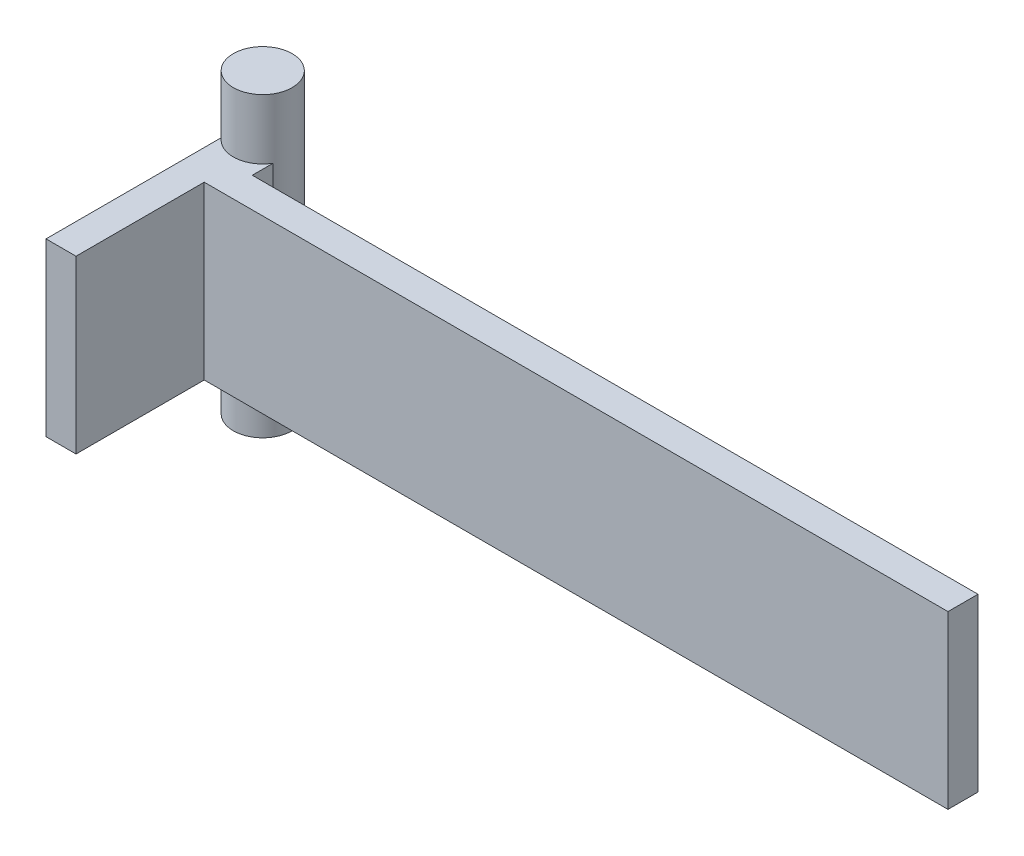
from build123d import *

# Parameters (mm, degrees)
SKETCH1_W                = 10
SKETCH1_H                = 28.53
BOSS_EXTRUDE1_DEPTH      = 5
SKETCH2_R                = 1.6
CUT_EXTRUDE2_DEPTH       = 43
SKETCH4_W                = 8
SKETCH4_H                = 28.530522497
BOSS_EXTRUDE2_DEPTH      = 5
BOSS_EXTRUDE2_DEPTH_BACK = 5
BOSS_EXTRUDE4_START      = -53
SKETCH6_W                = 5
SKETCH6_H                = 28.530522497
BOSS_EXTRUDE4_DEPTH      = 120.849702
SKETCH7_W                = 5
SKETCH7_H                = 28.530522497
BOSS_EXTRUDE5_DEPTH      = 26.35
SKETCH8_W                = 5
SKETCH8_H                = 7
BOSS_EXTRUDE6_DEPTH      = 21.504288
SKETCH9_W                = 5
SKETCH9_H                = 21.35
CUT_EXTRUDE3_DEPTH       = 22.504288
SKETCH10_R               = 4.9
BOSS_EXTRUDE7_DEPTH      = 49.5


with BuildPart() as part:
    # Sketch1 → Boss-Extrude1 (new body)
    with BuildSketch(Plane.XY):
        with Locations((5, -15.735)):
            Rectangle(SKETCH1_W, SKETCH1_H)
    extrude(amount=BOSS_EXTRUDE1_DEPTH)

    # Sketch2 → Cut-Extrude2 (cut)
    with BuildSketch(Plane(origin=(0, 0, 0), x_dir=(-1, 0, 0), z_dir=(0, 0, -1))):
        with Locations((-6.810310374, -9.47)):
            Circle(SKETCH2_R)
        with Locations((-6.810310374, -22)):
            Circle(SKETCH2_R)
    extrude(amount=-CUT_EXTRUDE2_DEPTH, mode=Mode.SUBTRACT)

    # Sketch4 → Boss-Extrude2 (add, two sides)
    with BuildSketch(Plane.XY) as boss_extrude2_sk:
        with Locations((-1, -15.734738752)):
            Rectangle(SKETCH4_W, SKETCH4_H)
    extrude(amount=BOSS_EXTRUDE2_DEPTH)
    extrude(boss_extrude2_sk.sketch, amount=-BOSS_EXTRUDE2_DEPTH_BACK)

    # Sketch6 → Boss-Extrude4 (add)
    with BuildSketch(Plane.ZY.offset(-70.84970239).offset(BOSS_EXTRUDE4_START)):
        with Locations((2.5, -15.734738752)):
            Rectangle(SKETCH6_W, SKETCH6_H)
    extrude(amount=BOSS_EXTRUDE4_DEPTH)

    # Sketch7 → Boss-Extrude5 (add)
    with BuildSketch(Plane(origin=(0, 0, 0), x_dir=(-1, 0, 0), z_dir=(0, 0, -1))):
        with Locations((2.5, -15.734738752)):
            Rectangle(SKETCH7_W, SKETCH7_H)
    extrude(amount=-BOSS_EXTRUDE5_DEPTH)

    # Sketch8 → Boss-Extrude6 (add)
    with BuildSketch(Plane(origin=(0, -1.469477503, 0), x_dir=(1, 0, 0), z_dir=(0, 1, 0))):
        with Locations((-2.5, -22.85)):
            Rectangle(SKETCH8_W, SKETCH8_H)
    extrude(amount=BOSS_EXTRUDE6_DEPTH)

    # Sketch9 → Cut-Extrude3 (cut, through all)
    with BuildSketch(Plane.XZ.offset(1.469477503)):
        with Locations((-2.5, 15.675)):
            Rectangle(SKETCH9_W, SKETCH9_H)
    extrude(amount=-CUT_EXTRUDE3_DEPTH, mode=Mode.SUBTRACT)


with BuildPart() as body_2:
    # Sketch10 → Boss-Extrude7 (new body)
    with BuildSketch(Plane.XZ.offset(40.965189842)):
        with Locations((-1.214108885, -5.955533219)):
            Circle(SKETCH10_R)
    extrude(amount=-BOSS_EXTRUDE7_DEPTH)


solid = Compound([part.part, body_2.part])
